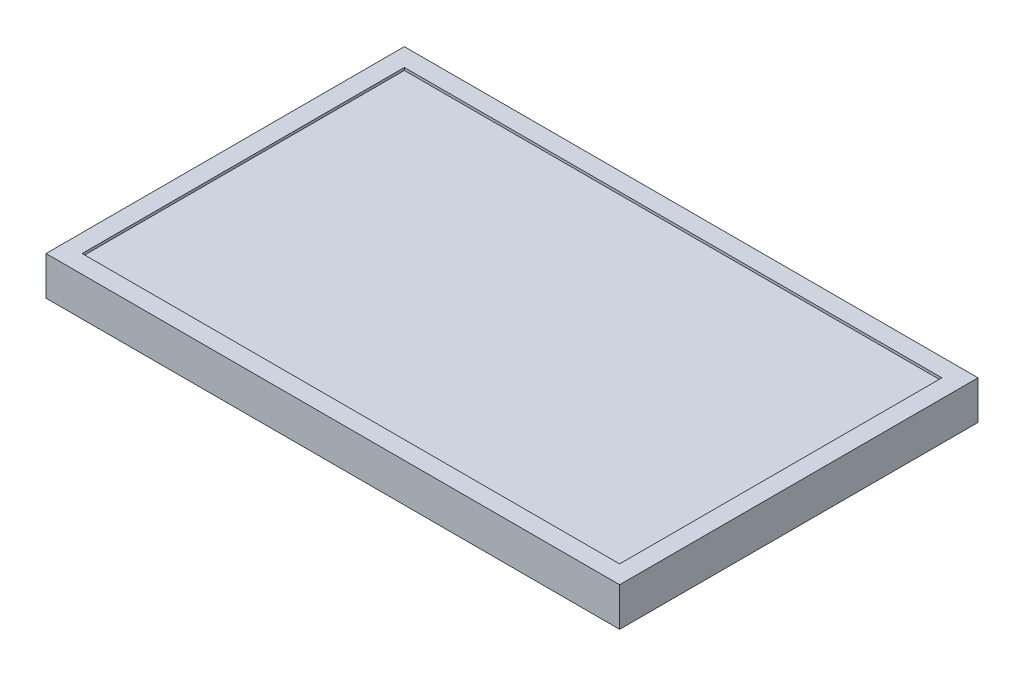
from build123d import *

# Parameters (mm, degrees)
SKETCH_1_W          = 445
SKETCH_1_H          = 278
EXTRUDE_1_DEPTH     = 30
SKETCH_2_W          = 417
SKETCH_2_H          = 250
CUT_EXTRUDE_1_DEPTH = 2


with BuildPart() as part:
    # 草圖1 → 填料-伸長1 (new body)
    with BuildSketch(Plane(origin=(0, 0, 0), x_dir=(1, 0, 0), z_dir=(0, 1, 0))):
        Rectangle(SKETCH_1_W, SKETCH_1_H)
    extrude(amount=EXTRUDE_1_DEPTH)

    # 草圖2 → 除料-伸長1 (cut)
    with BuildSketch(Plane(origin=(0, 30, 0), x_dir=(1, 0, 0), z_dir=(0, 1, 0))):
        Rectangle(SKETCH_2_W, SKETCH_2_H)
    extrude(amount=-CUT_EXTRUDE_1_DEPTH, mode=Mode.SUBTRACT)


solid = part.part
